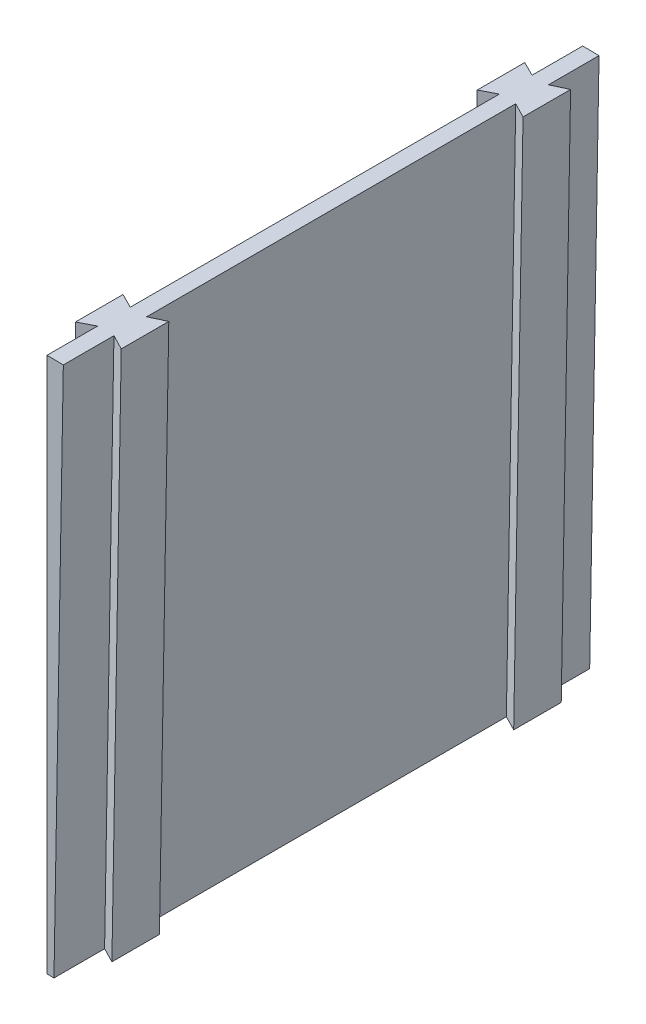
from build123d import *

# Parameters (mm, degrees)
BOSS_EXTRUDE1_DEPTH      = 101.6
BOSS_EXTRUDE2_REACH      = 145.703
BOSS_EXTRUDE2_END_RADIUS = 177.8
BOSS_EXTRUDE3_REACH      = 145.805
BOSS_EXTRUDE3_END_RADIUS = 177.8


with BuildPart() as part:
    # Sketch1 → Boss-Extrude1 (new body)
    with BuildSketch(Plane.XY):
        with BuildLine():
            Line((0, 76.2), (0, 177.8))
            ThreePointArc((0, 177.8), (1.551578012, 177.793229921), (3.103037865, 177.772920199))
            Line((3.103037865, 177.772920199), (1.329873371, 76.188394371))
            ThreePointArc((1.329873371, 76.188394371), (0.664962005, 76.197098537), (0, 76.2))
        make_face()
    extrude(amount=BOSS_EXTRUDE1_DEPTH)

    # Boss-Extrude2: up to this cylinder (the profile starts inside it)
    boss_extrude2_end = Plane(origin=(0, 0, 50.8), z_dir=(0, 0, -1)) * Cylinder(BOSS_EXTRUDE2_END_RADIUS, 724.206, mode=Mode.PRIVATE)
    # Sketch2 → Boss-Extrude2 (add, up to the surface)
    with BuildSketch(Plane(origin=(1.329873371, 76.188394371, 0), x_dir=(0, 0, -1), z_dir=(-0.01745240643728355, -0.9998476951563914, 0)), mode=Mode.PRIVATE) as boss_extrude2_sk1:
        Polygon((-92.000208065, 0), (-93.4085, 2.794), (-84.3915, 2.794), (-85.799791935, 0), align=None)
    boss_extrude2_tool1 = extrude(boss_extrude2_sk1.sketch, amount=-BOSS_EXTRUDE2_REACH, mode=Mode.PRIVATE) & boss_extrude2_end
    add(boss_extrude2_tool1.solids().sort_by_distance((2.812837, 76.162509, 88.9))[0])
    # Sketch2 → Boss-Extrude2 (add, up to the surface)
    with BuildSketch(Plane(origin=(1.329873371, 76.188394371, 0), x_dir=(0, 0, -1), z_dir=(-0.01745240643728355, -0.9998476951563914, 0)), mode=Mode.PRIVATE) as boss_extrude2_sk2:
        Polygon((-15.800208065, 0), (-9.599791935, 0), (-8.1915, 2.794), (-17.2085, 2.794), align=None)
    boss_extrude2_tool2 = extrude(boss_extrude2_sk2.sketch, amount=-BOSS_EXTRUDE2_REACH, mode=Mode.PRIVATE) & boss_extrude2_end
    add(boss_extrude2_tool2.solids().sort_by_distance((2.812837, 76.162509, 12.7))[0])

    # Boss-Extrude3: up to this cylinder (the profile starts inside it)
    boss_extrude3_end = Plane(origin=(0, 0, 50.8), z_dir=(0, 0, -1)) * Cylinder(BOSS_EXTRUDE3_END_RADIUS, 724.41, mode=Mode.PRIVATE)
    # Sketch3 → Boss-Extrude3 (add, up to the surface)
    with BuildSketch(Plane(origin=(0, 76.2, 0), x_dir=(0, 0, -1), z_dir=(0, -1, 0)), mode=Mode.PRIVATE) as boss_extrude3_sk1:
        Polygon((-92.000208065, 0), (-93.4085, -2.79357446), (-84.3915, -2.79357446), (-85.799791935, 0), align=None)
    boss_extrude3_tool1 = extrude(boss_extrude3_sk1.sketch, amount=-BOSS_EXTRUDE3_REACH, mode=Mode.PRIVATE) & boss_extrude3_end
    add(boss_extrude3_tool1.solids().sort_by_distance((-1.482964, 76.2, 88.9))[0])
    # Sketch3 → Boss-Extrude3 (add, up to the surface)
    with BuildSketch(Plane(origin=(0, 76.2, 0), x_dir=(0, 0, -1), z_dir=(0, -1, 0)), mode=Mode.PRIVATE) as boss_extrude3_sk2:
        Polygon((-15.800208065, 0), (-9.599791935, 0), (-8.1915, -2.79357446), (-17.2085, -2.79357446), align=None)
    boss_extrude3_tool2 = extrude(boss_extrude3_sk2.sketch, amount=-BOSS_EXTRUDE3_REACH, mode=Mode.PRIVATE) & boss_extrude3_end
    add(boss_extrude3_tool2.solids().sort_by_distance((-1.482964, 76.2, 12.7))[0])


solid = part.part
